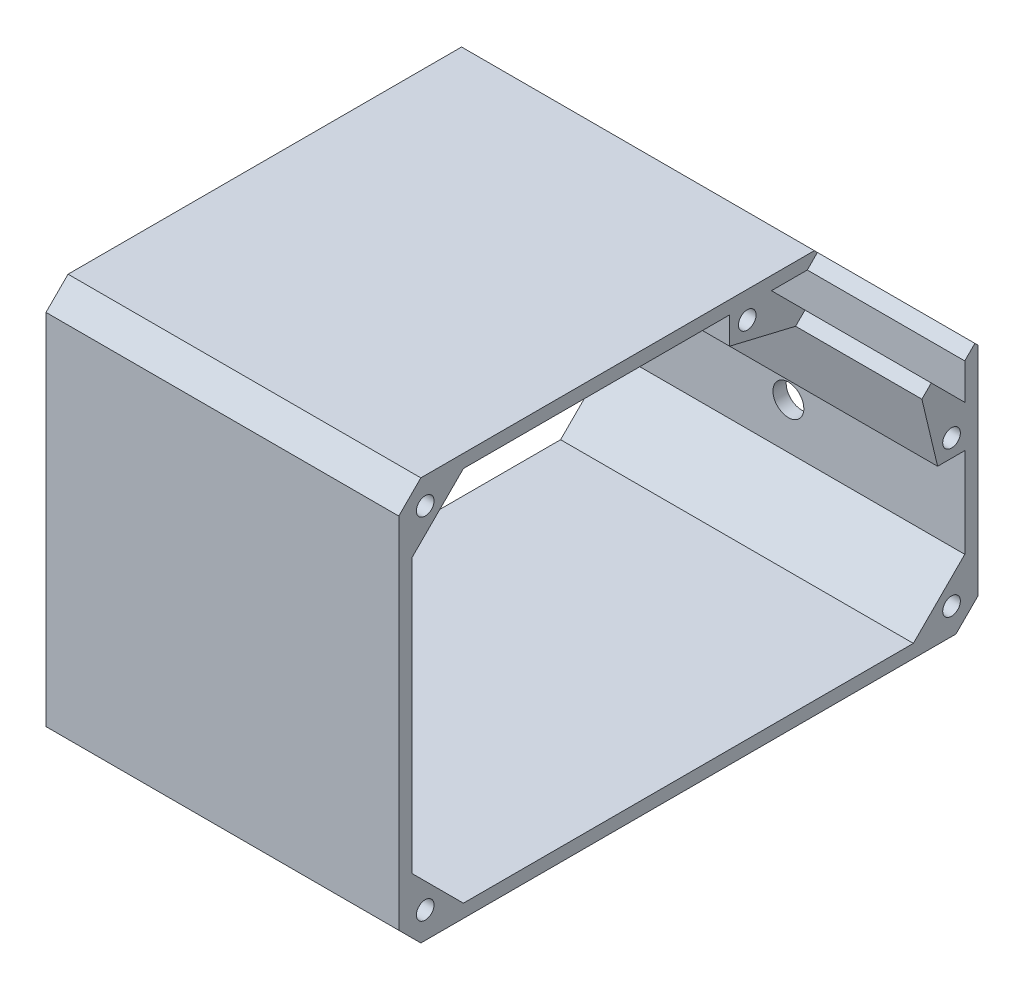
from build123d import *

# Parameters (mm, degrees)
SKETCH2_R           = 2
BOSS_EXTRUDE2_DEPTH = 80
CHAMFER2_SIZE       = 5
CUT_EXTRUDE1_REACH  = 133.355
SKETCH3_R           = 3.5


with BuildPart() as part:
    # Sketch2 → Boss-Extrude2 (new body)
    with BuildSketch(Plane(origin=(0, 0, 0), x_dir=(0, 0, -1), z_dir=(1, 0, 0))):
        Polygon((89.086021447, -37.960779863), (77.429167198, -49.617634112), (-24.612463363, -49.617634112), (-36.269317612, -37.960779863), (-36.269317612, 24.080850698), (-24.612463363, 35.737704947), (35.760119639, 35.737704947), (35.760119639, 29.578296595), (50.725478568, 26.014986706), (52.846798911, 28.136307049), (45.245401014, 35.737704947), (53.377128997, 35.737704947), (55.675226036, 38.035801986), (54.973323075, 38.737704947), (-39.269317612, 38.737704947), (-39.269317612, -52.617634112), (92.086021447, -52.617634112), (92.086021447, 1.625006575), (91.384118486, 2.326909536), (89.086021447, 0.028812497), (89.086021447, -8.102915487), (81.484279552, -0.501173592), (79.362959209, -2.622493935), (79.363303206, -2.622837932), (82.926613095, -17.588196861), (89.086021447, -17.588196861), align=None)
        with Locations((86.086021447, -46.617634112)):
            Circle(SKETCH2_R, mode=Mode.SUBTRACT)
        with Locations((-33.269317612, -46.617634112)):
            Circle(SKETCH2_R, mode=Mode.SUBTRACT)
        with Locations((86.086021447, -13.588196861)):
            Circle(SKETCH2_R, mode=Mode.SUBTRACT)
        with Locations((-33.269317612, 32.737704947)):
            Circle(SKETCH2_R, mode=Mode.SUBTRACT)
        with Locations((39.760119639, 32.737704947)):
            Circle(SKETCH2_R, mode=Mode.SUBTRACT)
    extrude(amount=BOSS_EXTRUDE2_DEPTH)

    # Chamfer2
    chamfer2_edges = [part.edges().sort_by_distance(p)[0] for p in [
        (40, -52.617634112, -92.086021447),
        (40, -52.617634112, 39.269317612),
        (40, 38.737704947, 39.269317612),
    ]]
    chamfer(chamfer2_edges, length=CHAMFER2_SIZE)

    # Sketch3 → Cut-Extrude1 (cut, up to next)
    with BuildSketch(Plane(origin=(0, 0, -92.086021447), x_dir=(-1, 0, 0), z_dir=(0, 0, -1)), mode=Mode.PRIVATE) as cut_extrude1_sk1:
        with Locations((-40, -27.617634112)):
            Circle(SKETCH3_R)
    cut_extrude1_tool1 = extrude(cut_extrude1_sk1.sketch, amount=-CUT_EXTRUDE1_REACH, mode=Mode.PRIVATE) & part.part
    add(cut_extrude1_tool1.solids().sort_by_distance((40, -27.617634, -92.086021))[0], mode=Mode.SUBTRACT)


solid = part.part
